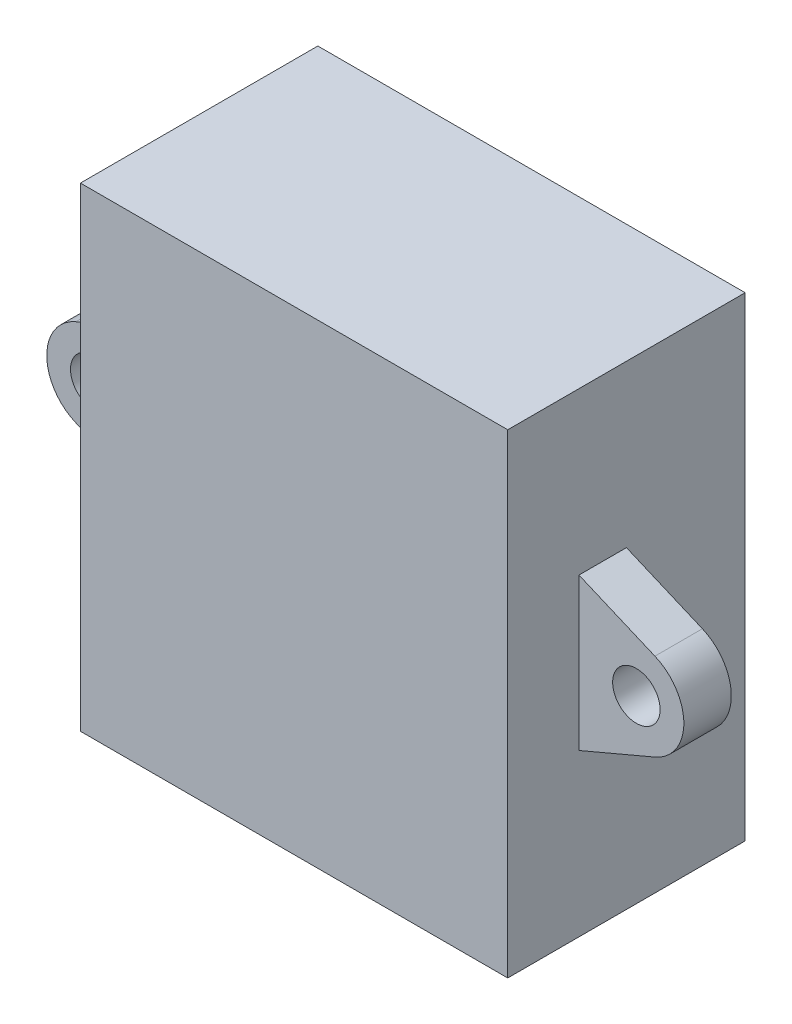
from build123d import *

# Parameters (mm, degrees)
SKETCH1_W           = 27
SKETCH1_H           = 30
BOSS_EXTRUDE3_DEPTH = 15
SKETCH5_R           = 1.5
BOSS_EXTRUDE7_DEPTH = 3


with BuildPart() as part:
    # Sketch1 → Boss-Extrude3 (new body)
    with BuildSketch(Plane.XY):
        with Locations((-43.997662922, -20.897486093)):
            Rectangle(SKETCH1_W, SKETCH1_H)
    extrude(amount=BOSS_EXTRUDE3_DEPTH)

    # Sketch5 → Boss-Extrude7 (add)
    with BuildSketch(Plane.XY.offset(7.5)):
        with BuildLine():
            Line((-30.497662922, -16.097486093), (-25.697662922, -18.13623415))
            ThreePointArc((-25.697662922, -18.13623415), (-23.870474804, -20.897486093), (-25.697662922, -23.658738035))
            Line((-25.697662922, -23.658738035), (-30.497662922, -25.697486093))
            Line((-30.497662922, -25.697486093), (-30.497662922, -16.097486093))
        make_face()
        with Locations((-26.870474804, -20.897486093)):
            Circle(SKETCH5_R, mode=Mode.SUBTRACT)
        with BuildLine():
            Line((-57.497662922, -16.097486093), (-57.497662922, -25.697486093))
            Line((-57.497662922, -25.697486093), (-62.297662922, -23.658738035))
            ThreePointArc((-62.297662922, -23.658738035), (-64.12485104, -20.897486093), (-62.297662922, -18.13623415))
            Line((-62.297662922, -18.13623415), (-57.497662922, -16.097486093))
        make_face()
        with Locations((-61.12485104, -20.897486093)):
            Circle(SKETCH5_R, mode=Mode.SUBTRACT)
    extrude(amount=BOSS_EXTRUDE7_DEPTH)


solid = part.part
